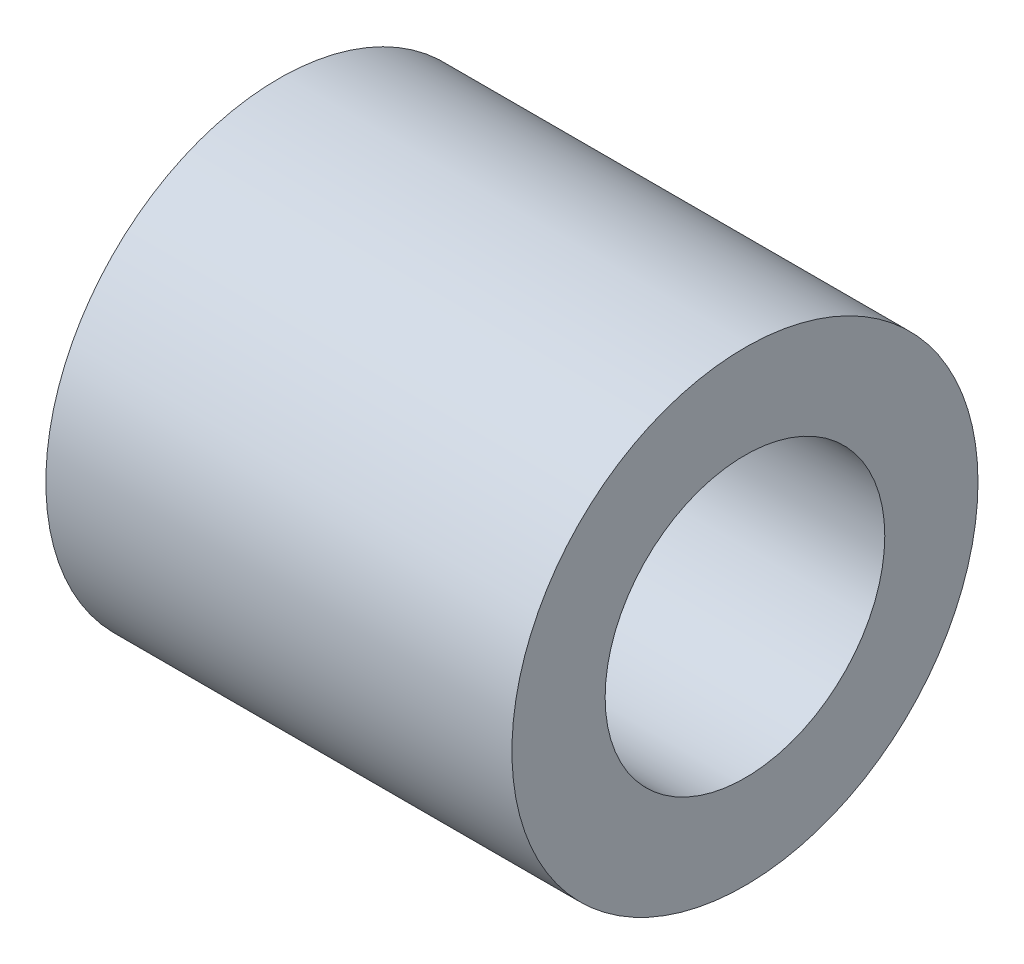
from build123d import *

# Parameters (mm, degrees)
SKETCH1_R           = 2.5
SKETCH1_R_2         = 1.5
BOSS_EXTRUDE1_DEPTH = 2.5


with BuildPart() as part:
    # Sketch1 → Boss-Extrude1 (new body, symmetric)
    with BuildSketch(Plane(origin=(0, 0, 0), x_dir=(0, 0, -1), z_dir=(1, 0, 0))):
        Circle(SKETCH1_R)
        Circle(SKETCH1_R_2, mode=Mode.SUBTRACT)
    extrude(amount=BOSS_EXTRUDE1_DEPTH, both=True)


solid = part.part
